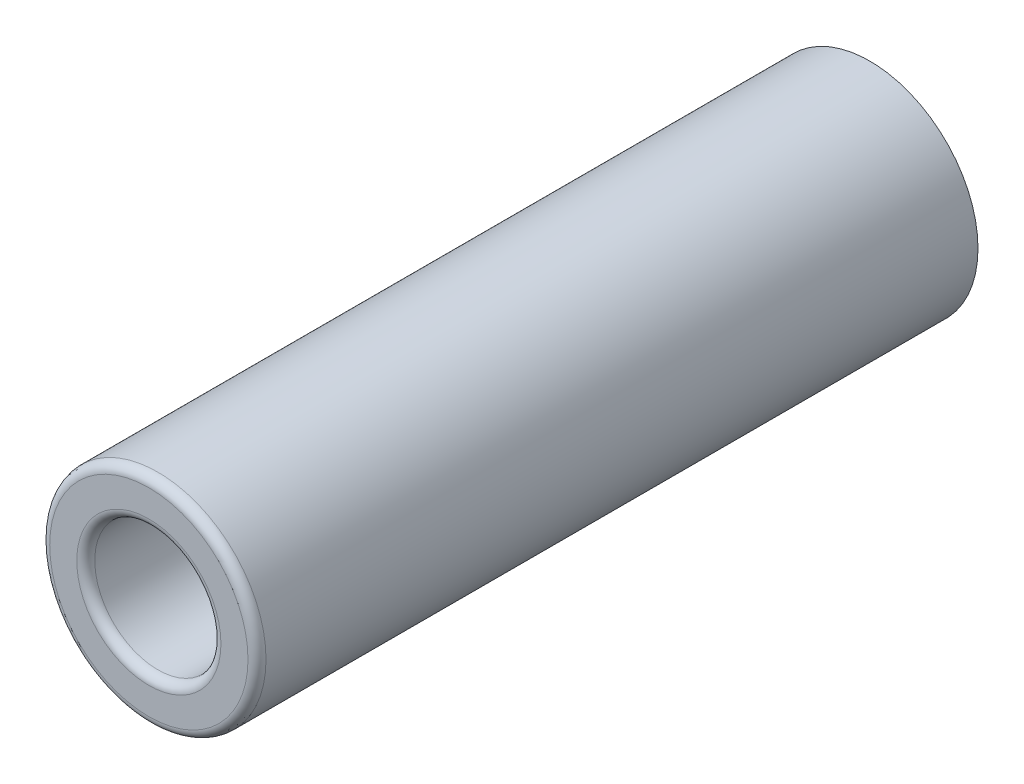
from build123d import *

# Parameters (mm, degrees)
SZKIC1_R                    = 6
SZKIC1_R_2                  = 3.5
DODANIE_WYCI_GNI_CIE1_DEPTH = 40
ZAOKR_GLENIE1_R             = 0.5
ZAOKR_GLENIE2_R             = 0.5


with BuildPart() as part:
    # Szkic1 → Dodanie-wyciągnięcie1 (new body)
    with BuildSketch(Plane.XY):
        Circle(SZKIC1_R)
        Circle(SZKIC1_R_2, mode=Mode.SUBTRACT)
    extrude(amount=DODANIE_WYCI_GNI_CIE1_DEPTH)

    # Zaokrąglenie1
    zaokr_glenie1_edges = [part.edges().sort_by_distance(p)[0] for p in [
        (-6, 0, 40),
    ]]
    fillet(zaokr_glenie1_edges, radius=ZAOKR_GLENIE1_R)

    # Zaokrąglenie2
    zaokr_glenie2_edges = [part.edges().sort_by_distance(p)[0] for p in [
        (-3.5, 0, 40),
    ]]
    fillet(zaokr_glenie2_edges, radius=ZAOKR_GLENIE2_R)


solid = part.part
